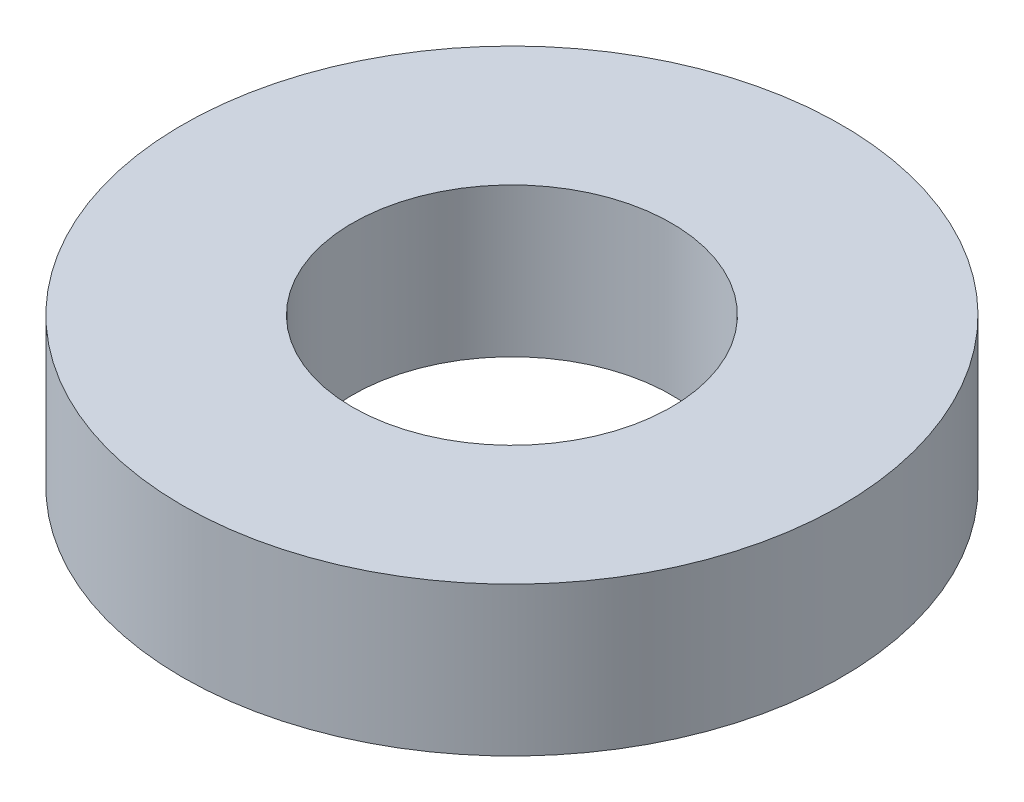
from build123d import *

# Parameters (mm, degrees)
SKETCH1_R           = 7.75
SKETCH1_R_2         = 3.75
BOSS_EXTRUDE1_DEPTH = 3.5


with BuildPart() as part:
    # Sketch1 → Boss-Extrude1 (new body)
    with BuildSketch(Plane(origin=(0, 0, 0), x_dir=(1, 0, 0), z_dir=(0, 1, 0))):
        Circle(SKETCH1_R)
        Circle(SKETCH1_R_2, mode=Mode.SUBTRACT)
    extrude(amount=BOSS_EXTRUDE1_DEPTH)


solid = part.part
